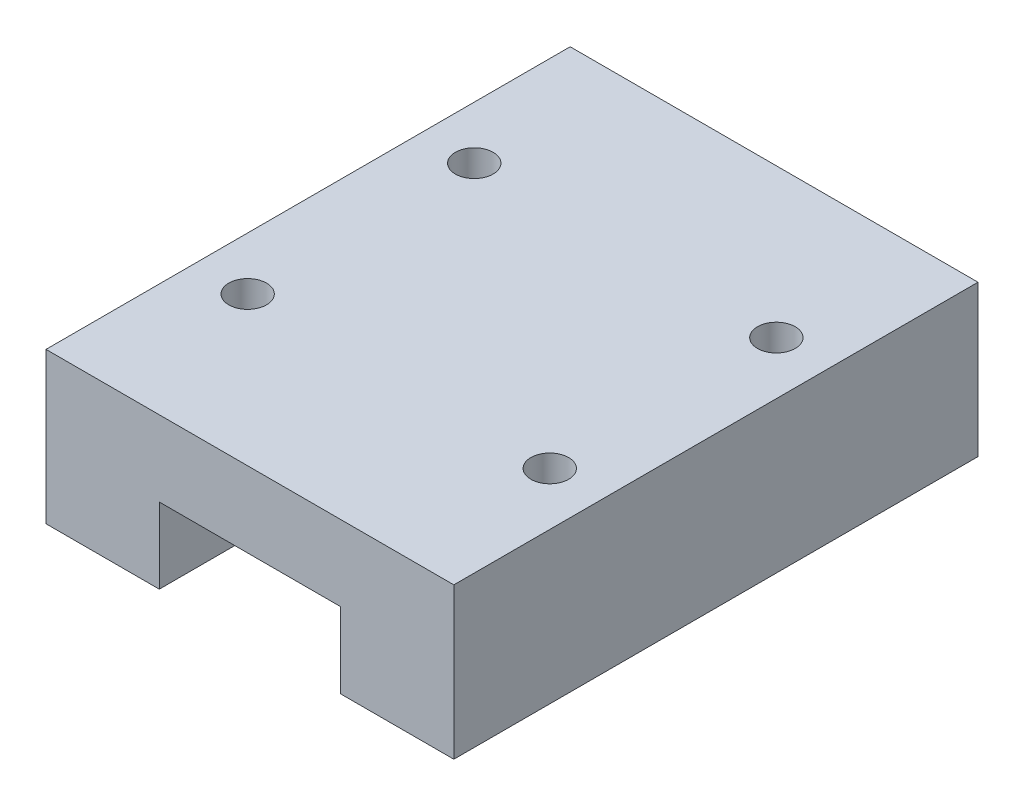
from build123d import *

# Parameters (mm, degrees)
SKETCH_1_W          = 27
SKETCH_1_H          = 10
EXTRUDE_1_DEPTH     = 34.7
SKETCH_2_W          = 12
SKETCH_2_H          = 5
CUT_EXTRUDE_1_DEPTH = 35.7
HOLE_WIZARD_M3_1_D  = 2.5


with BuildPart() as part:
    # 草图1 → 凸台-拉伸1 (new body)
    with BuildSketch(Plane.XY):
        with Locations((13.5, 5)):
            Rectangle(SKETCH_1_W, SKETCH_1_H)
    extrude(amount=EXTRUDE_1_DEPTH)

    # 草图2 → 切除-拉伸1 (cut, through all)
    with BuildSketch(Plane(origin=(0, 0, 0), x_dir=(-1, 0, 0), z_dir=(0, 0, -1))):
        with Locations((-13.5, 2.5)):
            Rectangle(SKETCH_2_W, SKETCH_2_H)
    extrude(amount=-CUT_EXTRUDE_1_DEPTH, mode=Mode.SUBTRACT)

    # M3 螺纹孔1 (through all)
    with Locations(Plane(origin=(0, 10, 0), x_dir=(1, 0, 0), z_dir=(0, 1, 0))):
        with Locations((23.5, -24.85), (23.5, -9.85), (3.5, -24.85), (3.5, -9.85)):
            Hole(HOLE_WIZARD_M3_1_D / 2)


solid = part.part
